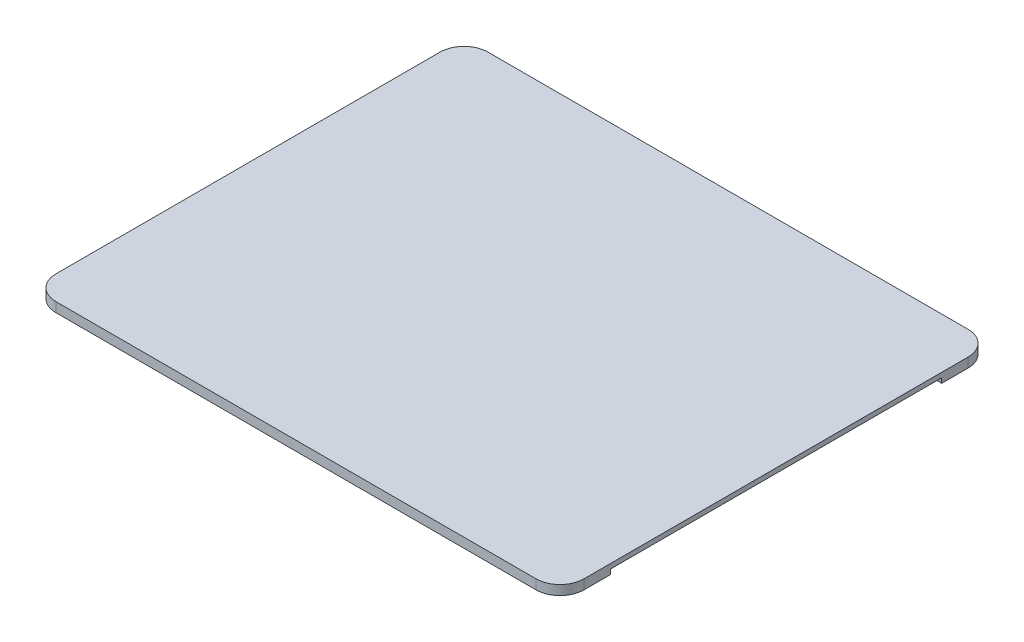
from build123d import *

# Parameters (mm, degrees)
SKETCH1_W           = 99
SKETCH1_H           = 79
BOSS_EXTRUDE1_DEPTH = 3
FILLET1_R           = 5
FILLET2_R           = 1
SKETCH2_W           = 110
SKETCH2_H           = 90
BOSS_EXTRUDE2_DEPTH = 2
FILLET3_R           = 5
SKETCH3_W           = 69
SKETCH3_H           = 1
CUT_EXTRUDE1_DEPTH  = 3


with BuildPart() as part:
    # Sketch1 → Boss-Extrude1 (new body)
    with BuildSketch(Plane(origin=(0, 0, 0), x_dir=(1, 0, 0), z_dir=(0, 1, 0))):
        Rectangle(SKETCH1_W, SKETCH1_H)
    extrude(amount=BOSS_EXTRUDE1_DEPTH)

    # Fillet1
    fillet1_edges = [part.edges().sort_by_distance(p)[0] for p in [
        (49.5, 1.5, 39.5),
        (-49.5, 1.5, 39.5),
        (-49.5, 1.5, -39.5),
        (49.5, 1.5, -39.5),
    ]]
    fillet(fillet1_edges, radius=FILLET1_R)

    # Fillet2
    fillet2_edges = [part.edges().sort_by_distance(p)[0] for p in [
        (0, 0, -39.5),
        (49.5, 0, 0),
        (0, 0, 39.5),
        (-49.5, 0, 0),
        (48.035533906, 0, 38.035533906),
        (-48.035533906, 0, 38.035533906),
        (-48.035533906, 0, -38.035533906),
        (48.035533906, 0, -38.035533906),
    ]]
    fillet(fillet2_edges, radius=FILLET2_R)

    # Sketch2 → Boss-Extrude2 (add)
    with BuildSketch(Plane(origin=(0, 3, 0), x_dir=(1, 0, 0), z_dir=(0, 1, 0))):
        Rectangle(SKETCH2_W, SKETCH2_H)
    extrude(amount=BOSS_EXTRUDE2_DEPTH)

    # Fillet3
    fillet3_edges = [part.edges().sort_by_distance(p)[0] for p in [
        (55, 4, 45),
        (55, 4, -45),
        (-55, 4, -45),
        (-55, 4, 45),
    ]]
    fillet(fillet3_edges, radius=FILLET3_R)

    # Sketch3 → Cut-Extrude1 (cut)
    with BuildSketch(Plane(origin=(55, 0, 0), x_dir=(0, 0, -1), z_dir=(1, 0, 0))):
        with Locations((0, 3.5)):
            Rectangle(SKETCH3_W, SKETCH3_H)
    cut_extrude1 = extrude(amount=-CUT_EXTRUDE1_DEPTH, mode=Mode.SUBTRACT)

    # Mirror1: Cut-Extrude1 across plane
    add(cut_extrude1.mirror(Plane(origin=(0, 0, 0), x_dir=(0, 0, 1), z_dir=(1, 0, 0))), mode=Mode.SUBTRACT)


solid = part.part
